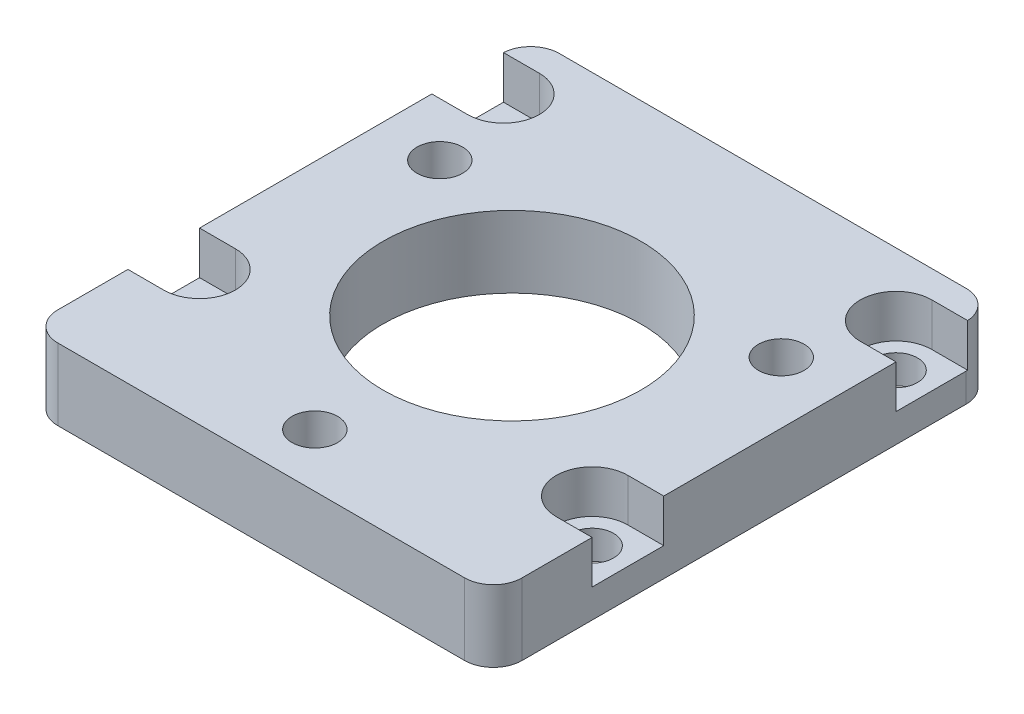
from build123d import *

# Parameters (mm, degrees)
SKETCH1_W                    = 41.148
SKETCH1_H                    = 44.45
BOSS_EXTRUDE1_DEPTH          = 6.35
FILLET1_R                    = 2.54
SKETCH2_R                    = 11.43
CUT_EXTRUDE1_DEPTH           = 7.35
F_25_0_1495_DIAMETER_HOLE1_D = 3.7973
F_10_32_TAPPED_HOLE2_D       = 4.0386
CUT_EXTRUDE2_DEPTH           = 3.81


with BuildPart() as part:
    # Sketch1 → Boss-Extrude1 (new body)
    with BuildSketch(Plane(origin=(0, 0, 0), x_dir=(1, 0, 0), z_dir=(0, 1, 0))):
        Rectangle(SKETCH1_W, SKETCH1_H)
    extrude(amount=BOSS_EXTRUDE1_DEPTH)

    # Fillet1
    fillet1_edges = [part.edges().sort_by_distance(p)[0] for p in [
        (-20.574, 3.175, -22.225),
        (20.574, 3.175, -22.225),
        (20.574, 3.175, 22.225),
        (-20.574, 3.175, 22.225),
    ]]
    fillet(fillet1_edges, radius=FILLET1_R)

    # Sketch2 → Cut-Extrude1 (cut, through all)
    with BuildSketch(Plane(origin=(0, 6.35, 0), x_dir=(1, 0, 0), z_dir=(0, 1, 0))):
        Circle(SKETCH2_R)
    extrude(amount=-CUT_EXTRUDE1_DEPTH, mode=Mode.SUBTRACT)

    # #25 (0.1495) Diameter Hole1 (through all)
    with Locations(Plane(origin=(-17.399, 6.35, -16.645384286), x_dir=(0, 0, 1), z_dir=(0, 1, 0))):
        with Locations((0, 0), (0, 34.798), (26.940768363, 34.798), (26.940768363, 0)):
            Hole(F_25_0_1495_DIAMETER_HOLE1_D / 2)

    # #10-32 Tapped Hole2 (through all)
    with Locations(Plane(origin=(-15.133967136, 6.35, -8.7376), x_dir=(0, 0, 1), z_dir=(0, 1, 0))):
        with Locations((0, 0), (0, 30.267934272), (26.2128, 15.133967136)):
            Hole(F_10_32_TAPPED_HOLE2_D / 2)

    # Sketch9 → Cut-Extrude2 (cut)
    with BuildSketch(Plane(origin=(0, 6.35, 0), x_dir=(1, 0, 0), z_dir=(0, 1, 0))):
        with BuildLine():
            Line((-20.574, 13.470384286), (-20.574, 19.820384286))
            Line((-20.574, 19.820384286), (-17.399, 19.820384286))
            ThreePointArc((-17.399, 19.820384286), (-14.224, 16.645384286), (-17.399, 13.470384286))
            Line((-17.399, 13.470384286), (-20.574, 13.470384286))
        make_face()
        with BuildLine():
            Line((17.399, 13.470384286), (20.574, 13.470384286))
            Line((20.574, 13.470384286), (20.574, 19.820384286))
            Line((20.574, 19.820384286), (17.399, 19.820384286))
            ThreePointArc((17.399, 19.820384286), (14.224, 16.645384286), (17.399, 13.470384286))
        make_face()
        with BuildLine():
            Line((20.574, -7.120384286), (20.574, -13.470384286))
            Line((20.574, -13.470384286), (17.399, -13.470384286))
            ThreePointArc((17.399, -13.470384286), (14.224, -10.295384286), (17.399, -7.120384286))
            Line((17.399, -7.120384286), (20.574, -7.120384286))
        make_face()
        with BuildLine():
            Line((-17.399, -7.120384286), (-20.574, -7.120384286))
            Line((-20.574, -7.120384286), (-20.574, -13.470384286))
            Line((-20.574, -13.470384286), (-17.399, -13.470384286))
            ThreePointArc((-17.399, -13.470384286), (-14.224, -10.295384286), (-17.399, -7.120384286))
        make_face()
    extrude(amount=-CUT_EXTRUDE2_DEPTH, mode=Mode.SUBTRACT)


solid = part.part
